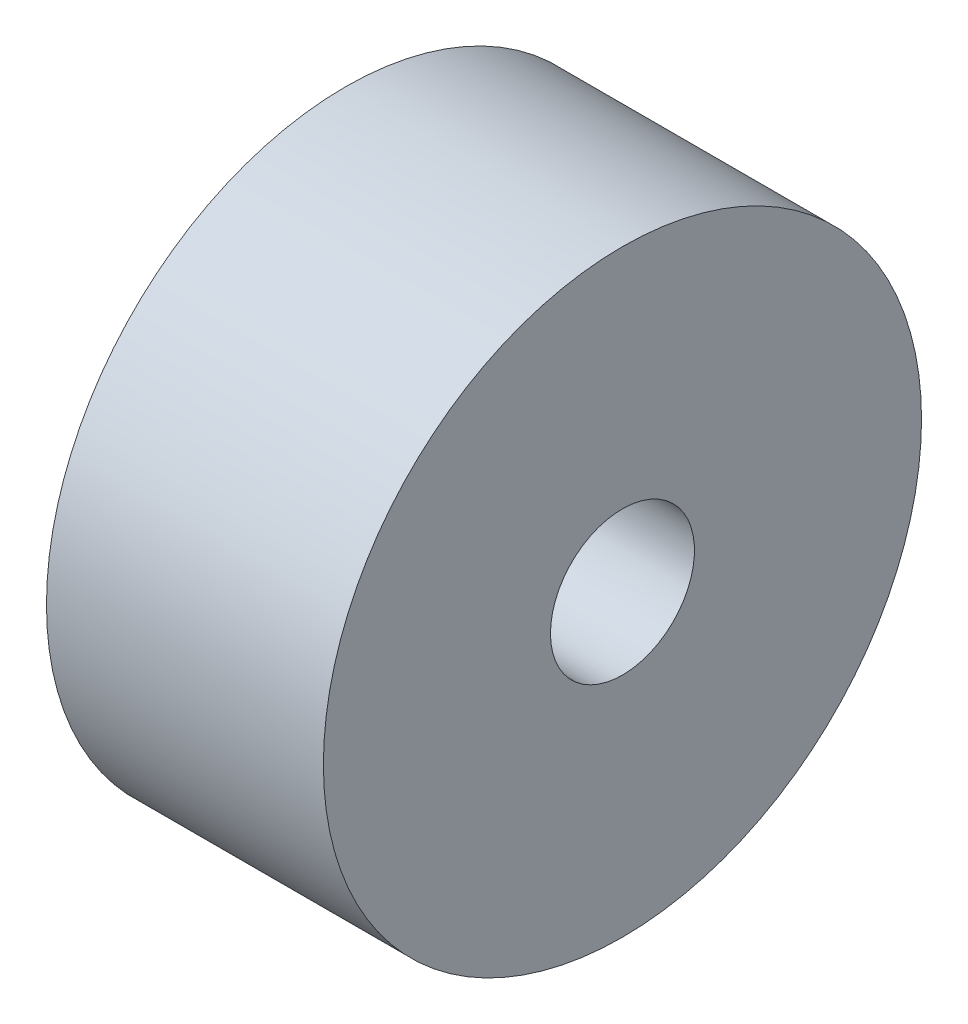
from build123d import *

# Parameters (mm, degrees)
SKIZZE1_W = 25
SKIZZE1_H = 20.5


with BuildPart() as part:
    # Skizze1 → Rotation1 (revolve)
    with BuildSketch(Plane.XY, mode=Mode.PRIVATE) as rotation1_sk:
        with Locations((0, 16.75)):
            Rectangle(SKIZZE1_W, SKIZZE1_H)
    revolve(rotation1_sk.sketch.rotate(Axis((0, 0, 0), (1, 0, 0)), 90), axis=Axis((0, 0, 0), (1, 0, 0)))  # turned: the seam where the file's is


solid = part.part
